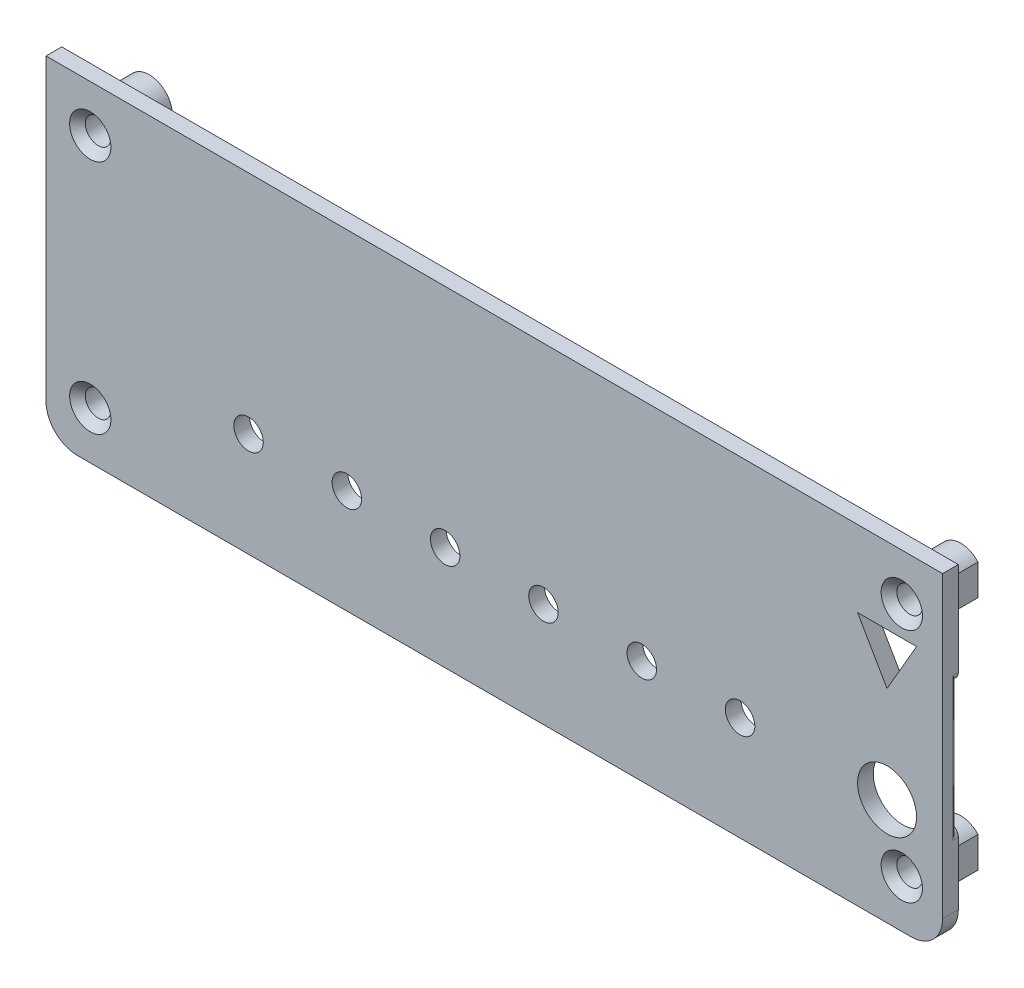
from build123d import *

# Parameters (mm, degrees)
EXTRUDE_1_DEPTH     = 1.6
SKETCH_3_W          = 84
SKETCH_3_H          = 26.4
EXTRUDE_1_2_DEPTH   = 2.8
CUT_EXTRUDE_1_DEPTH = 1.2
SKETCH_8_R          = 2.35345012
EXTRUDE_2_DEPTH     = 4.4
CUT_EXTRUDE_2_DEPTH = 0.2
FILLET_2_R          = 0.4
SKETCH_10_W         = 2.4
SKETCH_10_H         = 27.704592787
SKETCH_10_H_2       = 28.279400909
CUT_EXTRUDE_3_DEPTH = 12
SKETCH_11_R         = 1.3
CUT_EXTRUDE_4_DEPTH = 12
CHAMFER_1_SIZE      = 0.8
SKETCH_12_R         = 1.5
CUT_EXTRUDE_5_DEPTH = 12
SKETCH_13_R         = 3
CUT_EXTRUDE_6_DEPTH = 12
CUT_EXTRUDE_7_DEPTH = 1.2
SKETCH_15_R         = 1.5
EXTRUDE_4_DEPTH     = 1.6


with BuildPart() as part:
    # Эскиз2 → Extrude 1 (new body)
    with BuildSketch(Plane.XY):
        with BuildLine():
            Line((45.6, -13.6), (45.6, -7.203828964))
            Line((45.6, -7.203828964), (45.6, 7.296171036))
            Line((45.6, 7.296171036), (45.6, 16.8))
            Line((45.6, 16.8), (42.6, 16.8))
            Line((42.6, 16.8), (39.6, 16.8))
            Line((39.6, 16.8), (-39.6, 16.8))
            Line((-39.6, 16.8), (-42.6, 16.8))
            Line((-42.6, 16.8), (-45.6, 16.8))
            Line((-45.6, 16.8), (-45.6, -13.6))
            ThreePointArc((-45.6, -13.6), (-44.6627417, -15.8627417), (-42.4, -16.8))
            Line((-42.4, -16.8), (42.4, -16.8))
            ThreePointArc((42.4, -16.8), (44.6627417, -15.8627417), (45.6, -13.6))
        make_face()
    extrude(amount=EXTRUDE_1_DEPTH)

    # Эскиз3 → Extrude 1 2 (add)
    with BuildSketch(Plane.XY.offset(1.6)):
        with BuildLine():
            Line((-42.2, -15), (42.2, -15))
            ThreePointArc((42.2, -15), (43.33137085, -14.53137085), (43.8, -13.4))
            Line((43.8, -13.4), (43.8, 13.4))
            ThreePointArc((43.8, 13.4), (43.33137085, 14.53137085), (42.2, 15))
            Line((42.2, 15), (-42.2, 15))
            ThreePointArc((-42.2, 15), (-43.33137085, 14.53137085), (-43.8, 13.4))
            Line((-43.8, 13.4), (-43.8, -13.4))
            ThreePointArc((-43.8, -13.4), (-43.33137085, -14.53137085), (-42.2, -15))
        make_face()
        Rectangle(SKETCH_3_W, SKETCH_3_H, mode=Mode.SUBTRACT)
    extrude(amount=-EXTRUDE_1_2_DEPTH)

    # Эскиз4 → Вырез-Вытянуть-Тонкостенный1 (cut)
    with BuildSketch(Plane(origin=(0, 0, -1.2), x_dir=(-1, 0, 0), z_dir=(0, 0, -1))):
        with BuildLine():
            Line((-43.8, 13.4), (-43.8, -13.4))
            ThreePointArc((-43.8, -13.4), (-43.33137085, -14.53137085), (-42.2, -15))
            Line((-42.2, -15), (42.2, -15))
            ThreePointArc((42.2, -15), (43.33137085, -14.53137085), (43.8, -13.4))
            Line((43.8, -13.4), (43.8, 13.4))
            ThreePointArc((43.8, 13.4), (43.33137085, 14.53137085), (42.2, 15))
            Line((42.2, 15), (-42.2, 15))
            ThreePointArc((-42.2, 15), (-43.33137085, 14.53137085), (-43.8, 13.4))
        make_face()
        with BuildLine():
            Line((-43.2, 13.4), (-43.2, -13.4))
            ThreePointArc((-43.2, -13.4), (-42.907106781, -14.107106781), (-42.2, -14.4))
            Line((-42.2, -14.4), (42.2, -14.4))
            ThreePointArc((42.2, -14.4), (42.907106781, -14.107106781), (43.2, -13.4))
            Line((43.2, -13.4), (43.2, 13.4))
            ThreePointArc((43.2, 13.4), (42.907106781, 14.107106781), (42.2, 14.4))
            Line((42.2, 14.4), (-42.2, 14.4))
            ThreePointArc((-42.2, 14.4), (-42.907106781, 14.107106781), (-43.2, 13.4))
        make_face(mode=Mode.SUBTRACT)
    extrude(amount=-CUT_EXTRUDE_1_DEPTH, mode=Mode.SUBTRACT)

    # Эскиз8 → Бобышка-Вытянуть2 (add)
    with BuildSketch(Plane(origin=(0, 0, 0), x_dir=(-1, 0, 0), z_dir=(0, 0, -1))):
        with Locations((-41.44654988, 12.046171036)):
            Circle(SKETCH_8_R)
        with Locations((-41.44654988, -11.953828964)):
            Circle(SKETCH_8_R)
        with Locations((41.1, 12.046171036)):
            Circle(SKETCH_8_R)
        with Locations((41.1, -11.953828964)):
            Circle(SKETCH_8_R)
    extrude(amount=EXTRUDE_2_DEPTH)

    # Эскиз9 → Вырез-Вытянуть2 (cut)
    with BuildSketch(Plane(origin=(0, 0, 0), x_dir=(-1, 0, 0), z_dir=(0, 0, -1))):
        with BuildLine():
            Line((-44.8, -6.403828964), (-44.8, 6.496171036))
            ThreePointArc((-44.8, 6.496171036), (-45.365685425, 6.730485611), (-45.6, 7.296171036))
            Line((-45.6, 7.296171036), (-45.6, -7.203828964))
            ThreePointArc((-45.6, -7.203828964), (-45.365685425, -6.638143539), (-44.8, -6.403828964))
        make_face()
    extrude(amount=-CUT_EXTRUDE_2_DEPTH, mode=Mode.SUBTRACT)

    # Скругление2
    fillet_2_edges = [part.edges().sort_by_distance(p)[0] for p in [
        (45.6, 0.046171036, 0.2),
    ]]
    fillet(fillet_2_edges, radius=FILLET_2_R)

    # Эскиз10 → Вырез-Вытянуть3 (cut)
    with BuildSketch(Plane(origin=(0, 0, 0), x_dir=(-1, 0, 0), z_dir=(0, 0, -1))):
        with Locations((-44.4, 0.252296393)):
            Rectangle(SKETCH_10_W, SKETCH_10_H)
        with Locations((44.4, 0.539700455)):
            Rectangle(SKETCH_10_W, SKETCH_10_H_2)
    extrude(amount=CUT_EXTRUDE_3_DEPTH, mode=Mode.SUBTRACT)

    # Эскиз11 → Вырез-Вытянуть4 (cut)
    with BuildSketch(Plane(origin=(0, 0, -4.4), x_dir=(-1, 0, 0), z_dir=(0, 0, -1))):
        with Locations((-41.44654988, 12.046171036)):
            Circle(SKETCH_11_R)
        with Locations((-41.44654988, -11.953828964)):
            Circle(SKETCH_11_R)
        with Locations((41.1, -11.953828964)):
            Circle(SKETCH_11_R)
        with Locations((41.1, 12.046171036)):
            Circle(SKETCH_11_R)
    extrude(amount=-CUT_EXTRUDE_4_DEPTH, mode=Mode.SUBTRACT)

    # Фаска1
    chamfer_1_edges = [part.edges().sort_by_distance(p)[0] for p in [
        (-39.8, 12.046171036, 1.6),
        (-39.8, -11.953828964, 1.6),
        (42.74654988, -11.953828964, 1.6),
        (42.74654988, 12.046171036, 1.6),
    ]]
    chamfer(chamfer_1_edges, length=CHAMFER_1_SIZE)

    # Эскиз12 → Вырез-Вытянуть5 (cut)
    with BuildSketch(Plane(origin=(0, 0, 0), x_dir=(-1, 0, 0), z_dir=(0, 0, -1))):
        with Locations((-35, -6.2)):
            Circle(SKETCH_12_R)
        with Locations((-25, -6.2)):
            Circle(SKETCH_12_R)
        with Locations((-15, -6.2)):
            Circle(SKETCH_12_R)
        with Locations((-5, -6.2)):
            Circle(SKETCH_12_R)
        with Locations((5, -6.2)):
            Circle(SKETCH_12_R)
        with Locations((15, -6.2)):
            Circle(SKETCH_12_R)
        with Locations((25, -6.2)):
            Circle(SKETCH_12_R)
        with Locations((35, -6.2)):
            Circle(SKETCH_12_R)
    extrude(amount=-CUT_EXTRUDE_5_DEPTH, mode=Mode.SUBTRACT)

    # Эскиз13 → Вырез-Вытянуть6 (cut)
    with BuildSketch(Plane(origin=(0, 0, 0), x_dir=(-1, 0, 0), z_dir=(0, 0, -1))):
        with Locations((-39.94654988, -5.953828964)):
            Circle(SKETCH_13_R)
        Polygon((-42.94654988, 9.046171036), (-36.94654988, 9.046171036), (-39.94654988, 3.850018614), align=None)
    extrude(amount=-CUT_EXTRUDE_6_DEPTH, mode=Mode.SUBTRACT)

    # Эскиз14 → Вырез-Вытянуть7 (cut)
    with BuildSketch(Plane(origin=(0, 0, -1.2), x_dir=(-1, 0, 0), z_dir=(0, 0, -1))):
        with BuildLine():
            Line((-42, -9.666380509), (-42, 9.758722582))
            ThreePointArc((-42, 9.758722582), (-42.654530459, 10.026391249), (-43.2, 10.476413047))
            Line((-43.2, 10.476413047), (-43.2, -10.384070975))
            ThreePointArc((-43.2, -10.384070975), (-42.654530459, -9.934049177), (-42, -9.666380509))
        make_face()
    extrude(amount=-CUT_EXTRUDE_7_DEPTH, mode=Mode.SUBTRACT)

    # Эскиз15 → Бобышка-Вытянуть4 (add)
    with BuildSketch(Plane(origin=(0, 0, 0), x_dir=(-1, 0, 0), z_dir=(0, 0, -1))):
        with Locations((35, -6.2)):
            Circle(SKETCH_15_R)
        with Locations((-35, -6.2)):
            Circle(SKETCH_15_R)
    extrude(amount=-EXTRUDE_4_DEPTH)


solid = part.part
